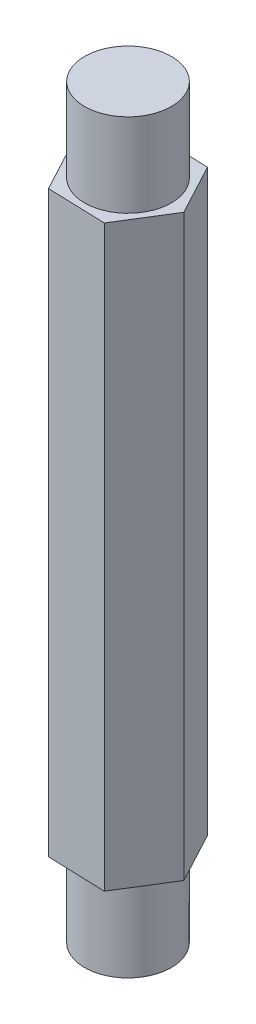
from build123d import *

# Parameters (mm, degrees)
BOSS_EXTRUDE1_DEPTH = 22
SKETCH2_R           = 1.65
BOSS_EXTRUDE2_DEPTH = 3.175
SKETCH3_R           = 1.65
BOSS_EXTRUDE3_DEPTH = 3.175


with BuildPart() as part:
    # Sketch1 → Boss-Extrude1 (new body)
    with BuildSketch(Plane(origin=(0, 0, 0), x_dir=(1, 0, 0), z_dir=(0, 1, 0))):
        Polygon((1.0344261, -1.934759928), (2.192764297, -0.071540683), (1.158338198, 1.863219245), (-1.0344261, 1.934759928), (-2.192764297, 0.071540683), (-1.158338198, -1.863219245), align=None)
    extrude(amount=BOSS_EXTRUDE1_DEPTH)

    # Sketch2 → Boss-Extrude2 (add)
    with BuildSketch(Plane(origin=(0, 22, 0), x_dir=(1, 0, 0), z_dir=(0, 1, 0))):
        Circle(SKETCH2_R)
    extrude(amount=BOSS_EXTRUDE2_DEPTH)

    # Sketch3 → Boss-Extrude3 (add)
    with BuildSketch(Plane.XZ):
        Circle(SKETCH3_R)
    extrude(amount=BOSS_EXTRUDE3_DEPTH)


solid = part.part
